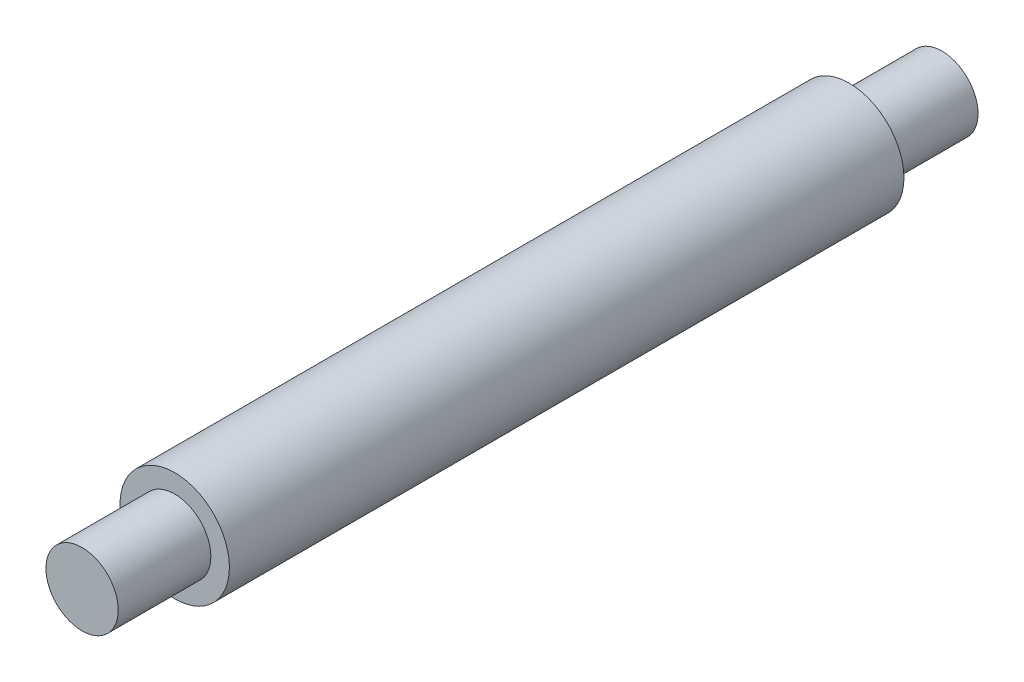
from build123d import *

# Parameters (mm, degrees)
SKETCH_1_R      = 2.95
EXTRUDE_1_DEPTH = 36.4
SKETCH_2_R      = 1.95
EXTRUDE_2_DEPTH = 5
SKETCH_3_R      = 1.95
EXTRUDE_3_DEPTH = 5


with BuildPart() as part:
    # ｽｹｯﾁ1 → ﾎﾞｽ - 押し出し1 (new body)
    with BuildSketch(Plane.XY):
        Circle(SKETCH_1_R)
    extrude(amount=EXTRUDE_1_DEPTH)

    # ｽｹｯﾁ2 → ﾎﾞｽ - 押し出し2 (add)
    with BuildSketch(Plane.XY.offset(36.4)):
        Circle(SKETCH_2_R)
    extrude(amount=EXTRUDE_2_DEPTH)

    # ｽｹｯﾁ3 → ﾎﾞｽ - 押し出し3 (add)
    with BuildSketch(Plane(origin=(0, 0, 0), x_dir=(-1, 0, 0), z_dir=(0, 0, -1))):
        Circle(SKETCH_3_R)
    extrude(amount=EXTRUDE_3_DEPTH)


solid = part.part
